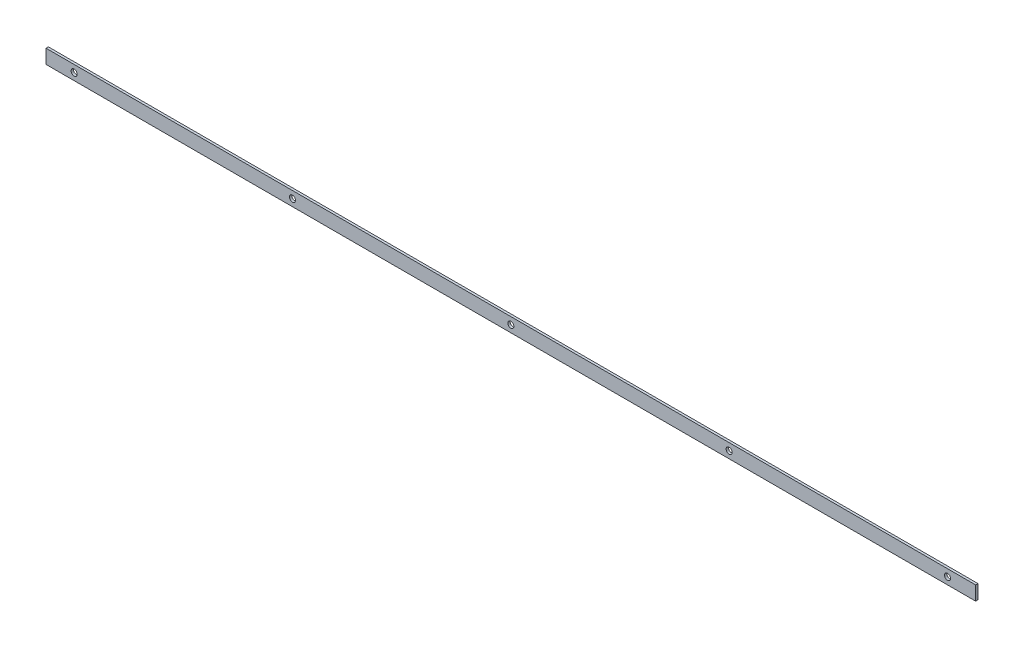
from build123d import *

# Parameters (mm, degrees)
PLAT_W                          = 30
PLAT_H                          = 5
EL_MENT_M_CANO_SOUD_1_DEPTH     = 1983
DIAM_TRE_DU_PER_AGE_13_0_13_1_D = 13
R_P_TITION_LIN_AIRE2_COUNT      = 5
R_P_TITION_LIN_AIRE2_PITCH      = 465.75


with BuildPart() as part:
    # plat → Elément mécano-soudé1 (new body)
    with BuildSketch(Plane.YZ.offset(-991.5)):
        Rectangle(PLAT_W, PLAT_H)
    extrude(amount=EL_MENT_M_CANO_SOUD_1_DEPTH)

    # Diamètre du perçage Ø13.0 (13)1 (through all)
    with Locations(Plane(origin=(0, 0, -2.5), x_dir=(-1, 0, 0), z_dir=(0, 0, -1))):
        with Locations((931.5, 0)):
            diam_tre_du_per_age_13_0_13_1 = Hole(DIAM_TRE_DU_PER_AGE_13_0_13_1_D / 2)

    # Répétition linéaire2: Diamètre du perçage Ø13.0 (13)1 ×5
    with Locations(*[(i * R_P_TITION_LIN_AIRE2_PITCH, 0, 0) for i in range(1, R_P_TITION_LIN_AIRE2_COUNT)]):
        add(diam_tre_du_per_age_13_0_13_1, mode=Mode.SUBTRACT)


solid = part.part
